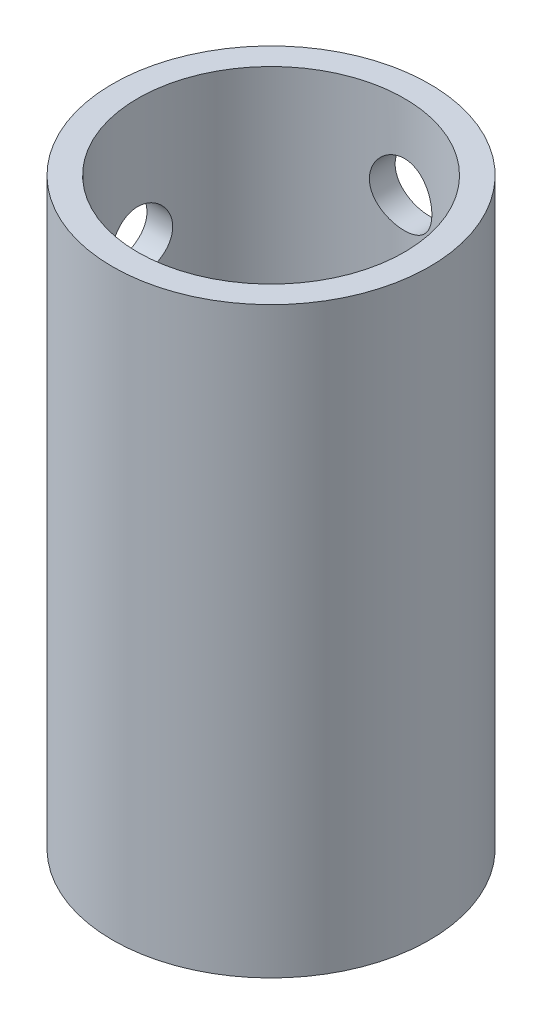
from build123d import *

# Parameters (mm, degrees)
SKETCH1_R           = 24.1554
SKETCH1_R_2         = 20.32
BOSS_EXTRUDE1_DEPTH = 88.9
SKETCH2_R           = 4.7625
CUT_EXTRUDE1_DEPTH  = 33.5788
SKETCH3_R           = 4.7625
CUT_EXTRUDE2_DEPTH  = 33.5788


with BuildPart() as part:
    # Sketch1 → Boss-Extrude1 (new body)
    with BuildSketch(Plane(origin=(0, 0, 0), x_dir=(1, 0, 0), z_dir=(0, 1, 0))):
        Circle(SKETCH1_R)
        Circle(SKETCH1_R_2, mode=Mode.SUBTRACT)
    extrude(amount=BOSS_EXTRUDE1_DEPTH)

    # Sketch2 → Cut-Extrude1 (cut)
    with BuildSketch(Plane.XY):
        with Locations((0, 76.2)):
            Circle(SKETCH2_R)
    extrude(amount=-CUT_EXTRUDE1_DEPTH, mode=Mode.SUBTRACT)

    # Sketch3 → Cut-Extrude2 (cut)
    with BuildSketch(Plane(origin=(0, 0, 0), x_dir=(0, 0, -1), z_dir=(1, 0, 0))):
        with Locations((0, 69.85)):
            Circle(SKETCH3_R)
    extrude(amount=-CUT_EXTRUDE2_DEPTH, mode=Mode.SUBTRACT)


solid = part.part
